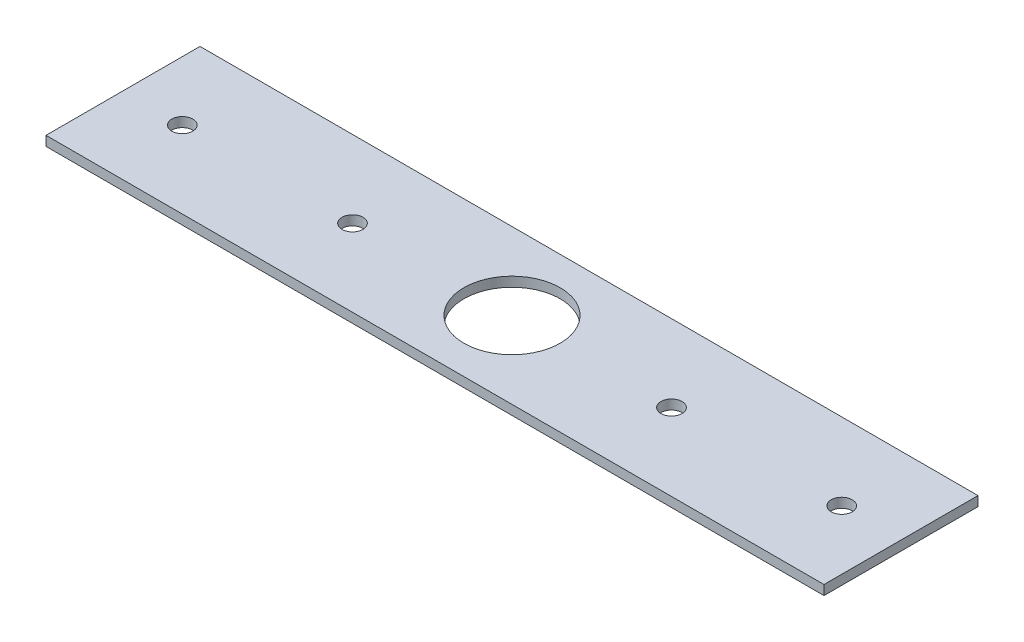
from build123d import *

# Parameters (mm, degrees)
SKETCH1_W           = 80.82
SKETCH1_H           = 16
SKETCH1_R           = 1.09
SKETCH1_R_2         = 5
BOSS_EXTRUDE1_DEPTH = 1


with BuildPart() as part:
    # Sketch1 → Boss-Extrude1 (new body)
    with BuildSketch(Plane(origin=(0, 0, 0), x_dir=(1, 0, 0), z_dir=(0, 1, 0))):
        with Locations((-0.885965444, 14.265677522)):
            Rectangle(SKETCH1_W, SKETCH1_H)
        with Locations((-35.135965444, 14.265677522)):
            Circle(SKETCH1_R, mode=Mode.SUBTRACT)
        with Locations((33.364034556, 14.265677522)):
            Circle(SKETCH1_R, mode=Mode.SUBTRACT)
        with Locations((-17.455965444, 14.265677522)):
            Circle(SKETCH1_R, mode=Mode.SUBTRACT)
        with Locations((15.684034556, 14.265677522)):
            Circle(SKETCH1_R, mode=Mode.SUBTRACT)
        with Locations((-0.885965444, 14.265677522)):
            Circle(SKETCH1_R_2, mode=Mode.SUBTRACT)
    extrude(amount=BOSS_EXTRUDE1_DEPTH)


solid = part.part
